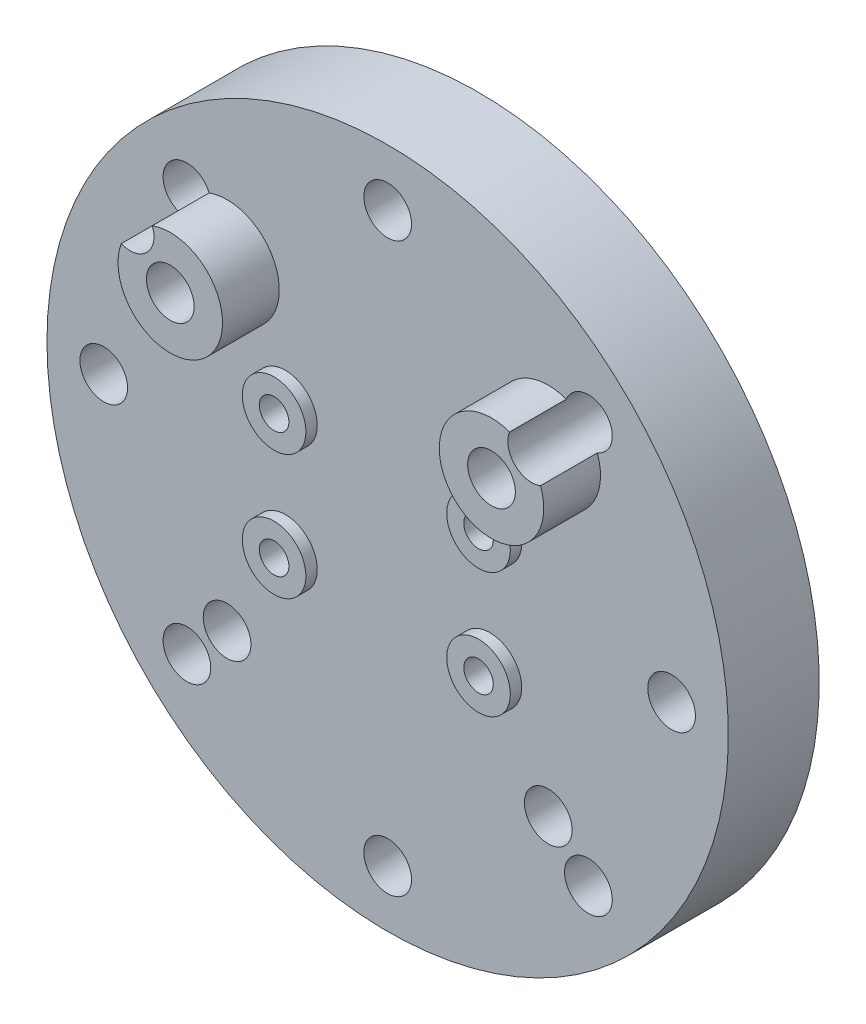
from build123d import *

# Parameters (mm, degrees)
ESQUISSE1_R             = 25
ESQUISSE1_R_2           = 2.1
ESQUISSE1_R_3           = 1.3
BOSS_EXTRU_1_DEPTH      = 2
ESQUISSE2_W             = 22
ESQUISSE2_H             = 10
ENL_V_MAT_EXTRU_1_DEPTH = 2
ESQUISSE3_R             = 2.8
ESQUISSE3_R_2           = 1.3
ESQUISSE3_R_3           = 4.6
ESQUISSE3_R_4           = 2.1
ESQUISSE3_R_5           = 3.6
BOSS_EXTRU_2_DEPTH      = 1
ESQUISSE4_OUTSIDE_W     = 66.154
ESQUISSE4_OUTSIDE_H     = 66.154
ENL_V_MAT_EXTRU_2_DEPTH = 4
CONG_1_R                = 2
ESQUISSE5_R             = 4.6
ESQUISSE5_R_2           = 2.1
BOSS_EXTRU_3_DEPTH      = 4
ESQUISSE6_R             = 30
ESQUISSE6_R_2           = 2.1
ESQUISSE6_R_3           = 1.3
BOSS_EXTRU_4_DEPTH      = 6
BOSS_EXTRU_4_DEPTH_BACK = 2
ESQUISSE7_R             = 2.1
ENL_V_MAT_EXTRU_3_DEPTH = 14
ESQUISSE8_R             = 3.6
ESQUISSE8_R_2           = 2.1
ENL_V_MAT_EXTRU_4_DEPTH = 3


with BuildPart() as part:
    # Esquisse1 → Boss.-Extru.1 (new body)
    with BuildSketch(Plane.XY):
        Circle(ESQUISSE1_R)
        with Locations((-14.142135624, 14.142135624)):
            Circle(ESQUISSE1_R_2, mode=Mode.SUBTRACT)
        with Locations((14.142135624, 14.142135624)):
            Circle(ESQUISSE1_R_2, mode=Mode.SUBTRACT)
        with Locations((-9, 5.5)):
            Circle(ESQUISSE1_R_3, mode=Mode.SUBTRACT)
        with Locations((-9, -5.5)):
            Circle(ESQUISSE1_R_3, mode=Mode.SUBTRACT)
        with Locations((9, 5.5)):
            Circle(ESQUISSE1_R_3, mode=Mode.SUBTRACT)
        with Locations((9, -5.5)):
            Circle(ESQUISSE1_R_3, mode=Mode.SUBTRACT)
    extrude(amount=BOSS_EXTRU_1_DEPTH)

    # Esquisse2 → Enlèv. mat.-Extru.1 (cut)
    with BuildSketch(Plane.XY.offset(2)):
        with Locations((0, -14)):
            Rectangle(ESQUISSE2_W, ESQUISSE2_H)
    extrude(amount=-ENL_V_MAT_EXTRU_1_DEPTH, mode=Mode.SUBTRACT)

    # Esquisse3 → Boss.-Extru.2 (add)
    with BuildSketch(Plane.XY.offset(2)):
        with Locations((-9, -5.5)):
            Circle(ESQUISSE3_R)
        with Locations((-9, -5.5)):
            Circle(ESQUISSE3_R_2, mode=Mode.SUBTRACT)
        with Locations((9, -5.5)):
            Circle(ESQUISSE3_R)
        with Locations((9, -5.5)):
            Circle(ESQUISSE3_R_2, mode=Mode.SUBTRACT)
        with Locations((9, 5.5)):
            Circle(ESQUISSE3_R)
        with Locations((9, 5.5)):
            Circle(ESQUISSE3_R_2, mode=Mode.SUBTRACT)
        with Locations((-9, 5.5)):
            Circle(ESQUISSE3_R)
        with Locations((-9, 5.5)):
            Circle(ESQUISSE3_R_2, mode=Mode.SUBTRACT)
        with Locations((-14.142135624, 14.142135624)):
            Circle(ESQUISSE3_R_3)
        with Locations((-14.142135624, 14.142135624)):
            Circle(ESQUISSE3_R_4, mode=Mode.SUBTRACT)
        with Locations((14.142135624, -14.142135624)):
            Circle(ESQUISSE3_R_5)
        with Locations((14.142135624, -14.142135624)):
            Circle(ESQUISSE3_R_4, mode=Mode.SUBTRACT)
        with Locations((-14.142135624, -14.142135624)):
            Circle(ESQUISSE3_R_5)
        with Locations((-14.142135624, -14.142135624)):
            Circle(ESQUISSE3_R_4, mode=Mode.SUBTRACT)
        with Locations((14.142135624, 14.142135624)):
            Circle(ESQUISSE3_R_3)
        with Locations((14.142135624, 14.142135624)):
            Circle(ESQUISSE3_R_4, mode=Mode.SUBTRACT)
    extrude(amount=BOSS_EXTRU_2_DEPTH)

    # Esquisse4 outside → Enlèv. mat.-Extru.2 (cut, through all)
    with BuildSketch(Plane(origin=(0, 0, 0), x_dir=(-1, 0, 0), z_dir=(0, 0, -1))):
        Rectangle(ESQUISSE4_OUTSIDE_W, ESQUISSE4_OUTSIDE_H)
        with BuildLine():
            Line((-14.142135624, 18.742135624), (14.142135624, 18.742135624))
            ThreePointArc((14.142135624, 18.742135624), (17.394826817, 17.394826817), (18.742135624, 14.142135624))
            Line((18.742135624, 14.142135624), (18.742135624, -9))
            Line((18.742135624, -9), (-18.742135624, -9))
            Line((-18.742135624, -9), (-18.742135624, 14.142135624))
            ThreePointArc((-18.742135624, 14.142135624), (-17.394826817, 17.394826817), (-14.142135624, 18.742135624))
        make_face(mode=Mode.SUBTRACT)
    extrude(amount=-ENL_V_MAT_EXTRU_2_DEPTH, mode=Mode.SUBTRACT)

    # Congé1
    cong_1_edges = [part.edges().sort_by_distance(p)[0] for p in [
        (-18.742135624, -9, 1),
        (18.742135624, -9, 1),
    ]]
    fillet(cong_1_edges, radius=CONG_1_R)

    # Esquisse5 → Boss.-Extru.3 (add)
    with BuildSketch(Plane.XY.offset(3)):
        with Locations((14.142135624, 14.142135624)):
            Circle(ESQUISSE5_R)
        with Locations((14.142135624, 14.142135624)):
            Circle(ESQUISSE5_R_2, mode=Mode.SUBTRACT)
        with Locations((-14.142135624, 14.142135624)):
            Circle(ESQUISSE5_R)
        with Locations((-14.142135624, 14.142135624)):
            Circle(ESQUISSE5_R_2, mode=Mode.SUBTRACT)
    extrude(amount=BOSS_EXTRU_3_DEPTH)

    # Esquisse6 → Boss.-Extru.4 (add, two sides)
    with BuildSketch(Plane(origin=(0, 0, 0), x_dir=(-1, 0, 0), z_dir=(0, 0, -1))) as boss_extru_4_sk:
        Circle(ESQUISSE6_R)
        with Locations((14.142135624, 14.142135624)):
            Circle(ESQUISSE6_R_2, mode=Mode.SUBTRACT)
        with Locations((9, 5.5)):
            Circle(ESQUISSE6_R_3, mode=Mode.SUBTRACT)
        with Locations((9, -5.5)):
            Circle(ESQUISSE6_R_3, mode=Mode.SUBTRACT)
        with Locations((-9, -5.5)):
            Circle(ESQUISSE6_R_3, mode=Mode.SUBTRACT)
        with Locations((-9, 5.5)):
            Circle(ESQUISSE6_R_3, mode=Mode.SUBTRACT)
        with Locations((-14.142135624, 14.142135624)):
            Circle(ESQUISSE6_R_2, mode=Mode.SUBTRACT)
    extrude(amount=BOSS_EXTRU_4_DEPTH)
    extrude(boss_extru_4_sk.sketch, amount=-BOSS_EXTRU_4_DEPTH_BACK)

    # Esquisse7 → Enlèv. mat.-Extru.3 (cut, through all)
    with BuildSketch(Plane(origin=(0, 0, -6), x_dir=(-1, 0, 0), z_dir=(0, 0, -1))):
        with Locations((-14.142135624, -14.142135624)):
            Circle(ESQUISSE7_R)
        with Locations((14.142135624, -14.142135624)):
            Circle(ESQUISSE7_R)
        with Locations((0, 25)):
            Circle(ESQUISSE7_R)
        with Locations((17.67766953, 17.67766953)):
            Circle(ESQUISSE7_R)
        with Locations((25, 0)):
            Circle(ESQUISSE7_R)
        with Locations((17.67766953, -17.67766953)):
            Circle(ESQUISSE7_R)
        with Locations((0, -25)):
            Circle(ESQUISSE7_R)
        with Locations((-17.67766953, -17.67766953)):
            Circle(ESQUISSE7_R)
        with Locations((-25, 0)):
            Circle(ESQUISSE7_R)
        with Locations((-17.67766953, 17.67766953)):
            Circle(ESQUISSE7_R)
    extrude(amount=-ENL_V_MAT_EXTRU_3_DEPTH, mode=Mode.SUBTRACT)

    # Esquisse8 → Enlèv. mat.-Extru.4 (cut)
    with BuildSketch(Plane(origin=(0, 0, -6), x_dir=(-1, 0, 0), z_dir=(0, 0, -1))):
        with Locations((-14.142135624, -14.142135624)):
            Circle(ESQUISSE8_R)
        with Locations((-14.142135624, -14.142135624)):
            Circle(ESQUISSE8_R_2, mode=Mode.SUBTRACT)
        with Locations((14.142135624, -14.142135624)):
            Circle(ESQUISSE8_R)
        with Locations((14.142135624, -14.142135624)):
            Circle(ESQUISSE8_R_2, mode=Mode.SUBTRACT)
        with Locations((14.142135624, 14.142135624)):
            Circle(ESQUISSE8_R)
        with Locations((14.142135624, 14.142135624)):
            Circle(ESQUISSE8_R_2, mode=Mode.SUBTRACT)
        with Locations((-14.142135624, 14.142135624)):
            Circle(ESQUISSE8_R)
        with Locations((-14.142135624, 14.142135624)):
            Circle(ESQUISSE8_R_2, mode=Mode.SUBTRACT)
    extrude(amount=-ENL_V_MAT_EXTRU_4_DEPTH, mode=Mode.SUBTRACT)


solid = part.part
